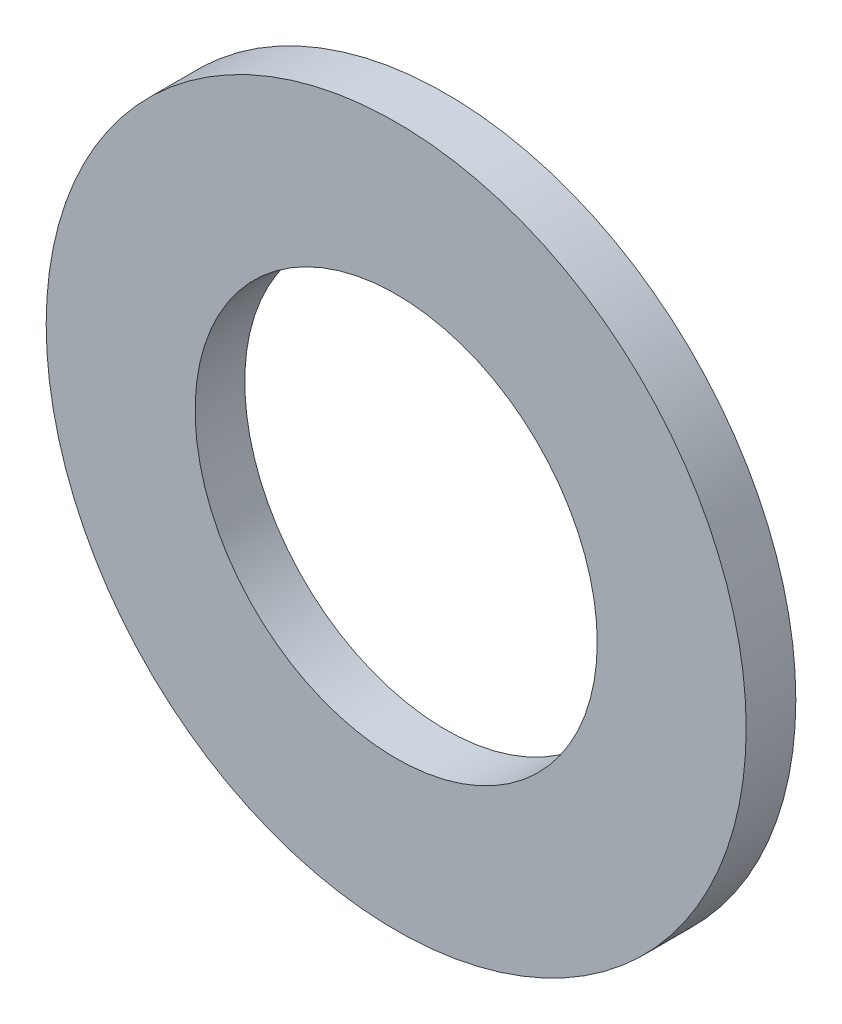
from build123d import *

# Parameters (mm, degrees)
SKETCH1_R           = 7.05
SKETCH1_R_2         = 4.05
BOSS_EXTRUDE1_DEPTH = 1


with BuildPart() as part:
    # Sketch1 → Boss-Extrude1 (new body)
    with BuildSketch(Plane.XY):
        Circle(SKETCH1_R)
        Circle(SKETCH1_R_2, mode=Mode.SUBTRACT)
    extrude(amount=BOSS_EXTRUDE1_DEPTH)


solid = part.part
